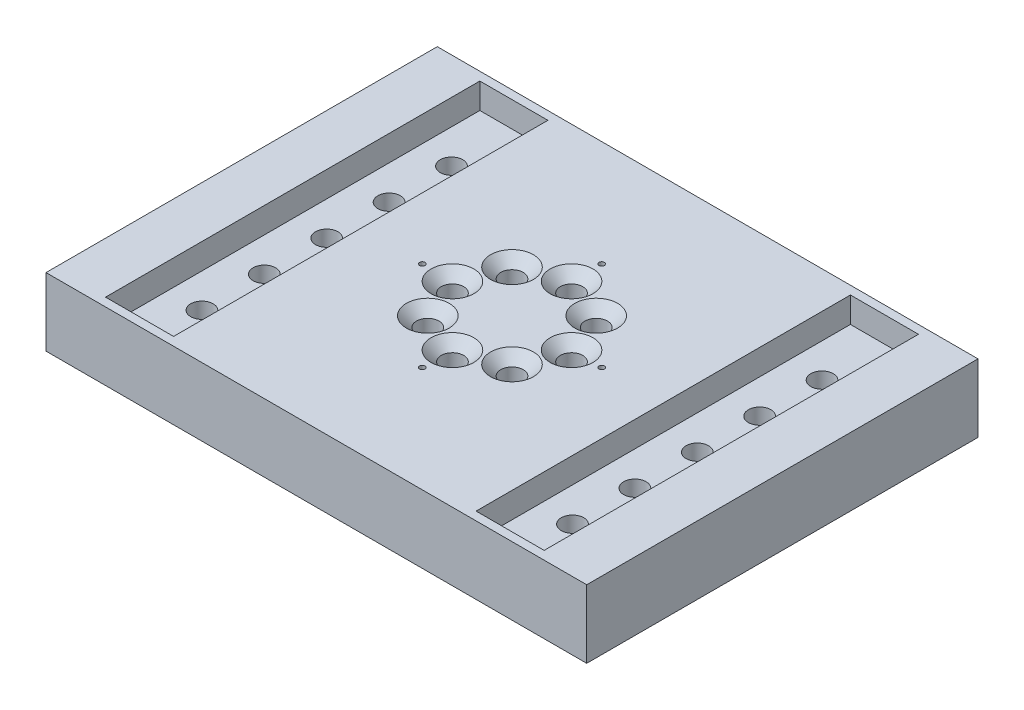
from build123d import *

# Parameters (mm, degrees)
SKETCH1_W                                       = 158.9
SKETCH1_H                                       = 114.98494382
BOSS_EXTRUDE1_DEPTH                             = 20
SKETCH2_R                                       = 44.45
CUT_EXTRUDE1_DEPTH                              = 5
SKETCH3_R                                       = 22.479
CUT_EXTRUDE2_DEPTH                              = 5.5
CSK_FOR_M6_FLAT_HEAD_MACHINE_SCREW1_D           = 6.6
CSK_FOR_M6_FLAT_HEAD_MACHINE_SCREW1_CSINK_D     = 12.6
CSK_FOR_M6_FLAT_HEAD_MACHINE_SCREW1_CSINK_ANGLE = 90
TAP_DRILL_FOR_M2X0_4_TAP1_D                     = 1.6
SKETCH18_W                                      = 20
SKETCH18_H                                      = 110
CUT_EXTRUDE3_DEPTH                              = 7.5
CSK_FOR_M6_FLAT_HEAD_MACHINE_SCREW2_D           = 6.6
CSK_FOR_M6_FLAT_HEAD_MACHINE_SCREW2_DEPTH       = 20
CSK_FOR_M6_FLAT_HEAD_MACHINE_SCREW2_CSINK_D     = 12.6
CSK_FOR_M6_FLAT_HEAD_MACHINE_SCREW2_CSINK_ANGLE = 90
CSK_FOR_M6_FLAT_HEAD_MACHINE_SCREW2_TIP         = 1.982840043


with BuildPart() as part:
    # Sketch1 → Boss-Extrude1 (new body)
    with BuildSketch(Plane(origin=(0, 0, 0), x_dir=(1, 0, 0), z_dir=(0, 1, 0))):
        Rectangle(SKETCH1_W, SKETCH1_H)
    extrude(amount=BOSS_EXTRUDE1_DEPTH)

    # Sketch2 → Cut-Extrude1 (cut)
    with BuildSketch(Plane.XZ):
        Circle(SKETCH2_R)
    extrude(amount=-CUT_EXTRUDE1_DEPTH, mode=Mode.SUBTRACT)

    # Sketch3 → Cut-Extrude2 (cut)
    with BuildSketch(Plane(origin=(0, 5, 0), x_dir=(-1, 0, 0), z_dir=(0, -1, 0))):
        Circle(SKETCH3_R)
    extrude(amount=-CUT_EXTRUDE2_DEPTH, mode=Mode.SUBTRACT)

    # CSK for M6 Flat Head Machine Screw1 (through all)
    with Locations(Plane(origin=(0, 20, 0), x_dir=(1, 0, 0), z_dir=(0, 1, 0))):
        with Locations((-17.5, 0), (-12.374368671, 12.374368671), (0, 17.5), (12.374368671, 12.374368671), (17.5, 0), (12.374368671, -12.374368671), (0, -17.5), (-12.374368671, -12.374368671)):
            CounterSinkHole(CSK_FOR_M6_FLAT_HEAD_MACHINE_SCREW1_D / 2, CSK_FOR_M6_FLAT_HEAD_MACHINE_SCREW1_CSINK_D / 2, counter_sink_angle=CSK_FOR_M6_FLAT_HEAD_MACHINE_SCREW1_CSINK_ANGLE)

    # Tap Drill for M2x0.4 Tap1 (through all)
    with Locations(Plane(origin=(0, 20, 0), x_dir=(1, 0, 0), z_dir=(0, 1, 0))):
        with Locations((-26.35, 0), (0, 26.35), (0, -26.35), (26.35, 0)):
            Hole(TAP_DRILL_FOR_M2X0_4_TAP1_D / 2)

    # Sketch18 → Cut-Extrude3 (cut)
    with BuildSketch(Plane(origin=(0, 20, 0), x_dir=(1, 0, 0), z_dir=(0, 1, 0))):
        with Locations((-54.45, 0)):
            Rectangle(SKETCH18_W, SKETCH18_H)
        with Locations((54.45, 0)):
            Rectangle(SKETCH18_W, SKETCH18_H)
    extrude(amount=-CUT_EXTRUDE3_DEPTH, mode=Mode.SUBTRACT)

    # CSK for M6 Flat Head Machine Screw2
    with Locations(Plane(origin=(0, 0, 0), x_dir=(-1, 0, 0), z_dir=(0, -1, 0))):
        with Locations((54.45, -36.666666667), (54.45, -18.333333333), (54.45, 0), (54.45, 18.333333333), (54.45, 36.666666667), (-54.45, 36.666666667), (-54.45, 18.333333333), (-54.45, 0), (-54.45, -18.333333333), (-54.45, -36.666666667)):
            CounterSinkHole(CSK_FOR_M6_FLAT_HEAD_MACHINE_SCREW2_D / 2, CSK_FOR_M6_FLAT_HEAD_MACHINE_SCREW2_CSINK_D / 2, depth=CSK_FOR_M6_FLAT_HEAD_MACHINE_SCREW2_DEPTH, counter_sink_angle=CSK_FOR_M6_FLAT_HEAD_MACHINE_SCREW2_CSINK_ANGLE)
            with Locations((0, 0, -(CSK_FOR_M6_FLAT_HEAD_MACHINE_SCREW2_DEPTH + CSK_FOR_M6_FLAT_HEAD_MACHINE_SCREW2_TIP / 2))):  # 118° drill point
                Cone(0, CSK_FOR_M6_FLAT_HEAD_MACHINE_SCREW2_D / 2, CSK_FOR_M6_FLAT_HEAD_MACHINE_SCREW2_TIP, mode=Mode.SUBTRACT)


solid = part.part
